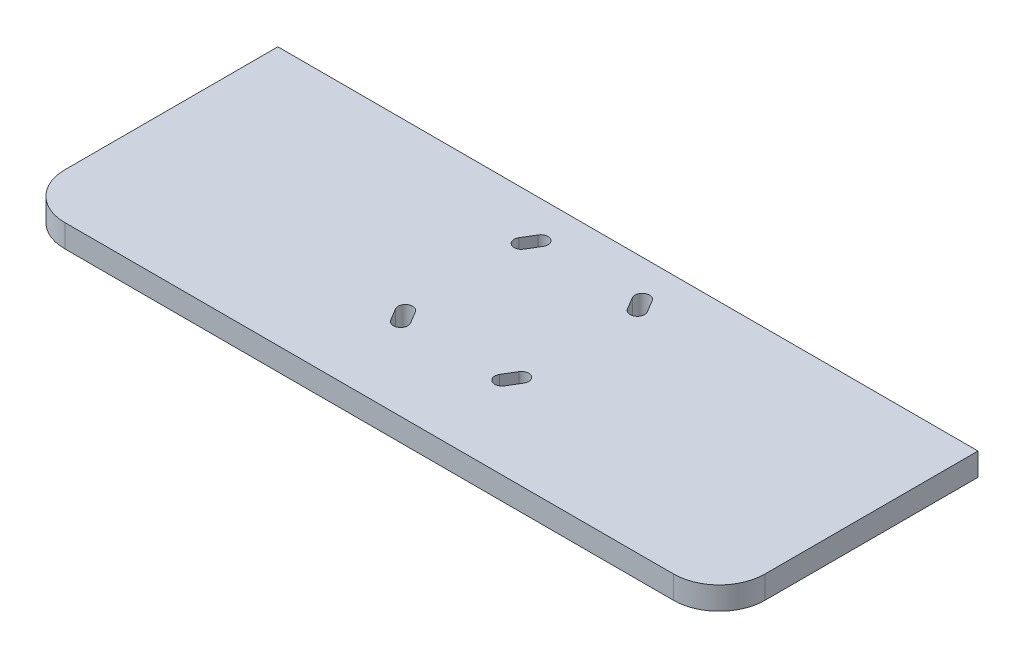
from build123d import *

# Parameters (mm, degrees)
BOSS_EXTRUDE1_DEPTH = 15
CUT_EXTRUDE2_DEPTH  = 16
SKETCH4_W           = 524.5681158
SKETCH4_H           = 94.971164408
CUT_EXTRUDE3_DEPTH  = 30


with BuildPart() as part:
    # Sketch1 → Boss-Extrude1 (new body)
    with BuildSketch(Plane(origin=(0, 0, 0), x_dir=(1, 0, 0), z_dir=(0, 1, 0))):
        with BuildLine():
            Line((-200, -100), (200, -100))
            ThreePointArc((200, -100), (221.213203436, -91.213203436), (230, -70))
            Line((230, -70), (230, 100))
            Line((230, 100), (-230, 100))
            Line((-230, 100), (-230, -70))
            ThreePointArc((-230, -70), (-221.213203436, -91.213203436), (-200, -100))
        make_face()
    extrude(amount=BOSS_EXTRUDE1_DEPTH)

    # Sketch3 → Cut-Extrude2 (cut, through all)
    with BuildSketch(Plane(origin=(0, 15, 0), x_dir=(1, 0, 0), z_dir=(0, 1, 0))):
        with BuildLine():
            Line((-2466.524123707, -5837.229065469), (-2474.461623707, -5841.991565469))
            ThreePointArc((-2474.461623707, -5841.991565469), (-2480.995719801, -5840.358041446), (-2479.362195777, -5833.823945352))
            Line((-2479.362195777, -5833.823945352), (-2471.424695777, -5829.061445352))
            ThreePointArc((-2471.424695777, -5829.061445352), (-2464.890599684, -5830.694969376), (-2466.524123707, -5837.229065469))
        make_face()
        with BuildLine():
            Line((-2466.524123707, -5905.261445352), (-2474.461623707, -5900.498945352))
            ThreePointArc((-2474.461623707, -5900.498945352), (-2480.995719801, -5902.132469376), (-2479.362195777, -5908.666565469))
            Line((-2479.362195777, -5908.666565469), (-2471.424695777, -5913.429065469))
            ThreePointArc((-2471.424695777, -5913.429065469), (-2464.890599684, -5911.795541446), (-2466.524123707, -5905.261445352))
        make_face()
        with BuildLine():
            Line((-2395.224695777, -5837.229065469), (-2387.287195777, -5841.991565469))
            ThreePointArc((-2387.287195777, -5841.991565469), (-2380.753099684, -5840.358041446), (-2382.386623707, -5833.823945352))
            Line((-2382.386623707, -5833.823945352), (-2390.324123707, -5829.061445352))
            ThreePointArc((-2390.324123707, -5829.061445352), (-2396.858219801, -5830.694969376), (-2395.224695777, -5837.229065469))
        make_face()
        with BuildLine():
            Line((-2395.224695777, -5905.261445352), (-2387.287195777, -5900.498945352))
            ThreePointArc((-2387.287195777, -5900.498945352), (-2380.753099684, -5902.132469376), (-2382.386623707, -5908.666565469))
            Line((-2382.386623707, -5908.666565469), (-2390.324123707, -5913.429065469))
            ThreePointArc((-2390.324123707, -5913.429065469), (-2396.858219801, -5911.795541446), (-2395.224695777, -5905.261445352))
        make_face()
        with BuildLine():
            Line((-34.016189941, -35.649713965), (-29.253689941, -43.587213965))
            ThreePointArc((-29.253689941, -43.587213965), (-30.887213965, -50.121310059), (-37.421310059, -48.487786035))
            Line((-37.421310059, -48.487786035), (-42.183810059, -40.550286035))
            ThreePointArc((-42.183810059, -40.550286035), (-40.550286035, -34.016189941), (-34.016189941, -35.649713965))
        make_face()
        with BuildLine():
            Line((34.016189941, -35.649713965), (29.253689941, -43.587213965))
            ThreePointArc((29.253689941, -43.587213965), (30.887213965, -50.121310059), (37.421310059, -48.487786035))
            Line((37.421310059, -48.487786035), (42.183810059, -40.550286035))
            ThreePointArc((42.183810059, -40.550286035), (40.550286035, -34.016189941), (34.016189941, -35.649713965))
        make_face()
        with BuildLine():
            Line((-34.016189941, 35.649713965), (-29.253689941, 43.587213965))
            ThreePointArc((-29.253689941, 43.587213965), (-30.887213965, 50.121310059), (-37.421310059, 48.487786035))
            Line((-37.421310059, 48.487786035), (-42.183810059, 40.550286035))
            ThreePointArc((-42.183810059, 40.550286035), (-40.550286035, 34.016189941), (-34.016189941, 35.649713965))
        make_face()
        with BuildLine():
            Line((34.016189941, 35.649713965), (29.253689941, 43.587213965))
            ThreePointArc((29.253689941, 43.587213965), (30.887213965, 50.121310059), (37.421310059, 48.487786035))
            Line((37.421310059, 48.487786035), (42.183810059, 40.550286035))
            ThreePointArc((42.183810059, 40.550286035), (40.550286035, 34.016189941), (34.016189941, 35.649713965))
        make_face()
    extrude(amount=-CUT_EXTRUDE2_DEPTH, mode=Mode.SUBTRACT)

    # Sketch4 → Cut-Extrude3 (cut)
    with BuildSketch(Plane(origin=(0, 0, -100), x_dir=(-1, 0, 0), z_dir=(0, 0, -1))):
        Rectangle(SKETCH4_W, SKETCH4_H)
    extrude(amount=-CUT_EXTRUDE3_DEPTH, mode=Mode.SUBTRACT)


solid = part.part
